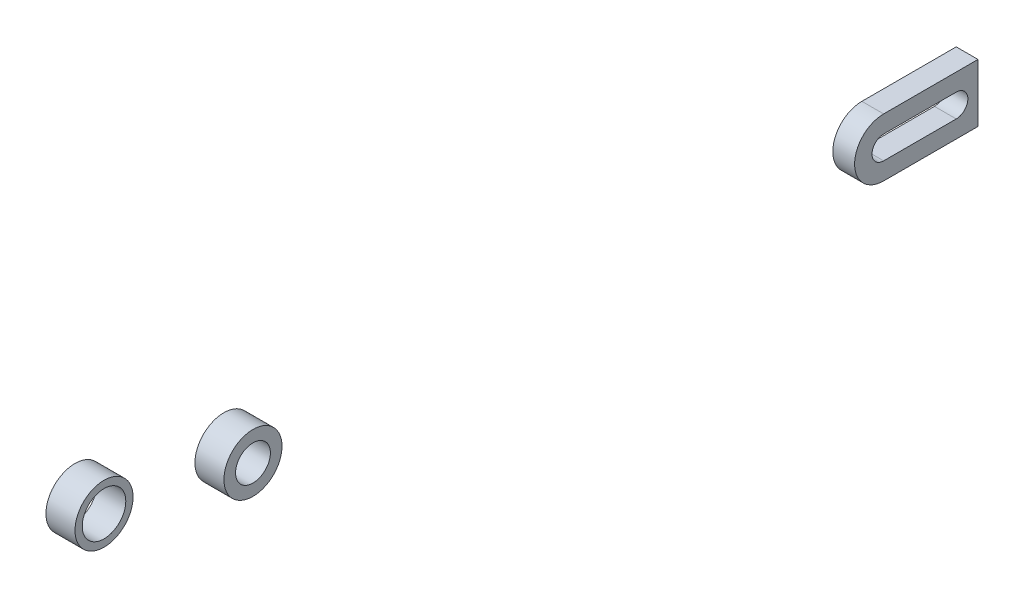
from build123d import *

# Parameters (mm, degrees)
RAMA_START               = -55
SZKIC_INSERT_RAMA_R      = 20
SZKIC_INSERT_RAMA_R_2    = 15
RAMA_DEPTH               = 10
LINKAGE_START            = 25
SZKIC_INSERT_LINKAGE_R   = 20
SZKIC_INSERT_LINKAGE_R_2 = 12
LINKAGE_DEPTH            = 20
TYLNE_KO_O_DEPTH         = 15


with BuildPart() as part:
    # Szkic - insert - rama → Rama (new body, symmetric)
    with BuildSketch(Plane(origin=(135, 0, 0), x_dir=(0, 0, -1), z_dir=(1, 0, 0)).offset(RAMA_START)):
        Circle(SZKIC_INSERT_RAMA_R)
        Circle(SZKIC_INSERT_RAMA_R_2, mode=Mode.SUBTRACT)
    extrude(amount=RAMA_DEPTH, both=True)


with BuildPart() as body_2:
    # Szkic - insert - linkage → Linkage (new body)
    with BuildSketch(Plane(origin=(0, 0, 0), x_dir=(0, 0, -1), z_dir=(1, 0, 0)).offset(LINKAGE_START)):
        with Locations((147.6, -66)):
            Circle(SZKIC_INSERT_LINKAGE_R)
        with Locations((147.6, -66)):
            Circle(SZKIC_INSERT_LINKAGE_R_2, mode=Mode.SUBTRACT)
    extrude(amount=LINKAGE_DEPTH)


with BuildPart() as body_3:
    # Szkic - insert - tylne koło → Tylne koło (new body)
    with BuildSketch(Plane(origin=(125, 0, 0), x_dir=(0, 0, -1), z_dir=(1, 0, 0))):
        with BuildLine():
            Line((487, 20), (552, 20))
            Line((552, 20), (552, -20))
            Line((552, -20), (487, -20))
            ThreePointArc((487, -20), (467, 0), (487, 20))
        make_face()
        with BuildLine():
            Line((537, 8), (487, 8))
            ThreePointArc((487, 8), (479, 0), (487, -8))
            Line((487, -8), (537, -8))
            ThreePointArc((537, -8), (545, 0), (537, 8))
        make_face(mode=Mode.SUBTRACT)
    extrude(amount=TYLNE_KO_O_DEPTH)


solid = Compound([part.part, body_2.part, body_3.part])
